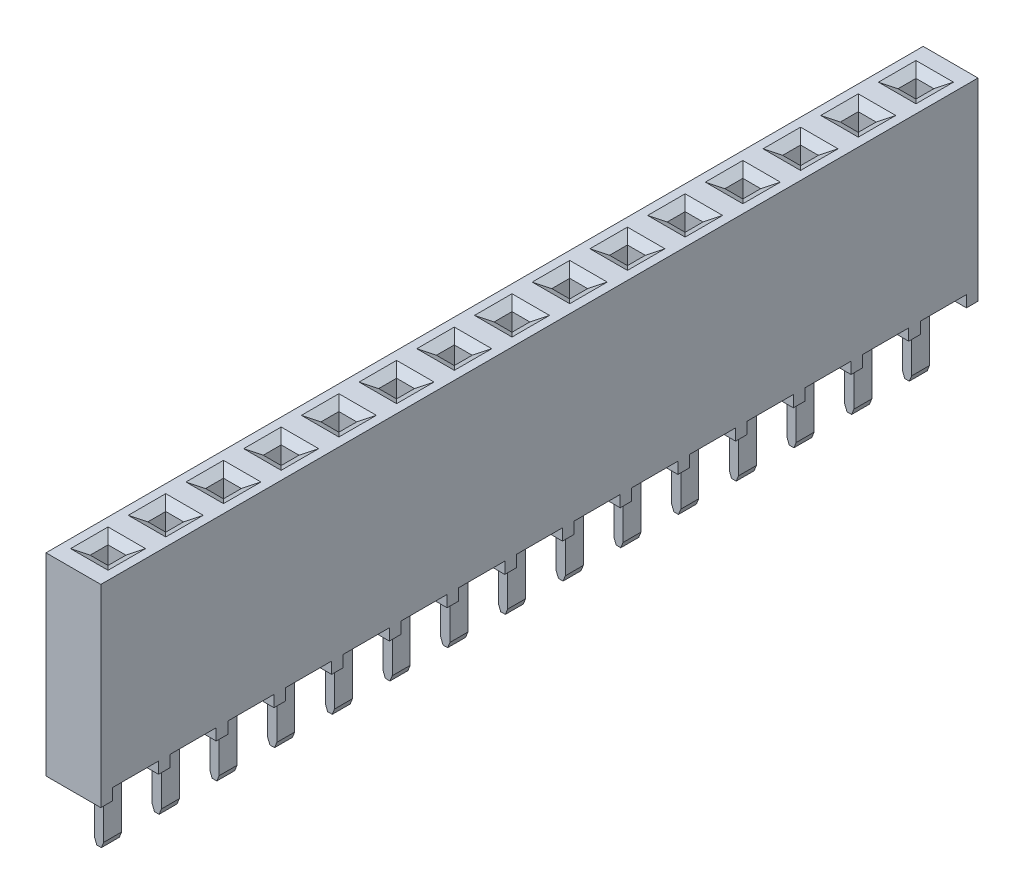
from build123d import *

# Parameters (mm, degrees)
SKETCH1_W                   = 2.413
SKETCH1_H                   = 38.608
MAIN_BODY_DEPTH             = 8.509
SKETCH5_W                   = 2.032
SKETCH5_H                   = 0.508
CUT_EXTRUDE2_DEPTH          = 2.413
LPATTERN1_COUNT             = 15
LPATTERN1_PITCH             = 2.54
SKETCH2_W                   = 0.7874
SKETCH2_H                   = 0.7874
CUT_EXTRUDE1_DEPTH          = 9.509
CHAMFER1_SIZE2              = 0.249299846
CHAMFER1_SIZE               = 0.4318
LPATTERN2_COUNT             = 15
LPATTERN2_PITCH             = 2.54
CHAMFER1_OF_LPATTERN2_SIZE2 = 0.249299846
CHAMFER1_OF_LPATTERN2_SIZE  = 0.4318
PIN_DEPTH                   = 0.3937
LPATTERN4_COUNT             = 15
LPATTERN4_PITCH             = 2.54


with BuildPart() as part:
    # Sketch1 → Main Body (new body)
    with BuildSketch(Plane(origin=(0, 0, 0), x_dir=(1, 0, 0), z_dir=(0, 1, 0))):
        Rectangle(SKETCH1_W, SKETCH1_H)
    extrude(amount=MAIN_BODY_DEPTH)

    # Sketch5 → Cut-Extrude2 (cut)
    with BuildSketch(Plane(origin=(1.2065, 0, 0), x_dir=(0, 0, -1), z_dir=(1, 0, 0))):
        with Locations((17.78, 0.254)):
            Rectangle(SKETCH5_W, SKETCH5_H)
    cut_extrude2 = extrude(amount=-CUT_EXTRUDE2_DEPTH, mode=Mode.SUBTRACT)

    # LPattern1: Cut-Extrude2 ×15
    with Locations(*[(0, 0, i * LPATTERN1_PITCH) for i in range(1, LPATTERN1_COUNT)]):
        add(cut_extrude2, mode=Mode.SUBTRACT)

    # Sketch2 → Cut-Extrude1 (cut, through all)
    with BuildSketch(Plane(origin=(0, 8.509, 0), x_dir=(-1, 0, 0), z_dir=(0, 1, 0))):
        with Locations((0, -17.78)):
            Rectangle(SKETCH2_W, SKETCH2_H)
    cut_extrude1 = extrude(amount=-CUT_EXTRUDE1_DEPTH, mode=Mode.SUBTRACT)

    # Chamfer1
    chamfer1_edges = [part.edges().sort_by_distance(p)[0] for p in [
        (0.3937, 8.509, -17.78),
        (0, 8.509, -18.1737),
        (-0.3937, 8.509, -17.78),
        (0, 8.509, -17.3863),
    ]]
    chamfer(chamfer1_edges, length=CHAMFER1_SIZE, length2=CHAMFER1_SIZE2)

    # LPattern2: Cut-Extrude1 ×15
    with Locations(*[(0, 0, i * LPATTERN2_PITCH) for i in range(1, LPATTERN2_COUNT)]):
        add(cut_extrude1, mode=Mode.SUBTRACT)

    # Chamfer1 of LPattern2
    chamfer1_of_lpattern2_edges = [part.edges().sort_by_distance(p)[0] for p in [
        (0.3937, 8.509, -15.24),
        (0, 8.509, -15.6337),
        (-0.3937, 8.509, -15.24),
        (0, 8.509, -14.8463),
        (0.3937, 8.509, -12.7),
        (0, 8.509, -13.0937),
        (-0.3937, 8.509, -12.7),
        (0, 8.509, -12.3063),
        (0.3937, 8.509, -10.16),
        (0, 8.509, -10.5537),
        (-0.3937, 8.509, -10.16),
        (0, 8.509, -9.7663),
        (0.3937, 8.509, -7.62),
        (0, 8.509, -8.0137),
        (-0.3937, 8.509, -7.62),
        (0, 8.509, -7.2263),
        (0.3937, 8.509, -5.08),
        (0, 8.509, -5.4737),
        (-0.3937, 8.509, -5.08),
        (0, 8.509, -4.6863),
        (0.3937, 8.509, -2.54),
        (0, 8.509, -2.9337),
        (-0.3937, 8.509, -2.54),
        (0, 8.509, -2.1463),
        (0.3937, 8.509, 0),
        (0, 8.509, -0.3937),
        (-0.3937, 8.509, 0),
        (0, 8.509, 0.3937),
        (0.3937, 8.509, 2.54),
        (0, 8.509, 2.1463),
        (-0.3937, 8.509, 2.54),
        (0, 8.509, 2.9337),
        (0.3937, 8.509, 5.08),
        (0, 8.509, 4.6863),
        (-0.3937, 8.509, 5.08),
        (0, 8.509, 5.4737),
        (0.3937, 8.509, 7.62),
        (0, 8.509, 7.2263),
        (-0.3937, 8.509, 7.62),
        (0, 8.509, 8.0137),
        (0.3937, 8.509, 10.16),
        (0, 8.509, 9.7663),
        (-0.3937, 8.509, 10.16),
        (0, 8.509, 10.5537),
        (0.3937, 8.509, 12.7),
        (0, 8.509, 12.3063),
        (-0.3937, 8.509, 12.7),
        (0, 8.509, 13.0937),
        (0.3937, 8.509, 15.24),
        (0, 8.509, 14.8463),
        (-0.3937, 8.509, 15.24),
        (0, 8.509, 15.6337),
        (0.3937, 8.509, 17.78),
        (0, 8.509, 17.3863),
        (-0.3937, 8.509, 17.78),
        (0, 8.509, 18.1737),
    ]]
    chamfer(chamfer1_of_lpattern2_edges, length=CHAMFER1_OF_LPATTERN2_SIZE, length2=CHAMFER1_OF_LPATTERN2_SIZE2)

    # Sketch4 → PIN (add, symmetric)
    with BuildSketch(Plane(origin=(0, 0, -17.78), x_dir=(-1, 0, 0), z_dir=(0, 0, -1))):
        Polygon((-0.3937, 1.016), (0.3937, 1.016), (0.3937, 0.889), (0.2032, 0.889), (0.2032, -2.3876), (0.1016, -2.6416), (-0.1016, -2.6416), (-0.2032, -2.3876), (-0.2032, 0.889), (-0.3937, 0.889), align=None)
    pin = extrude(amount=PIN_DEPTH, both=True)

    # LPattern4: PIN ×15
    with Locations(*[(0, 0, i * LPATTERN4_PITCH) for i in range(1, LPATTERN4_COUNT)]):
        add(pin)


solid = part.part
